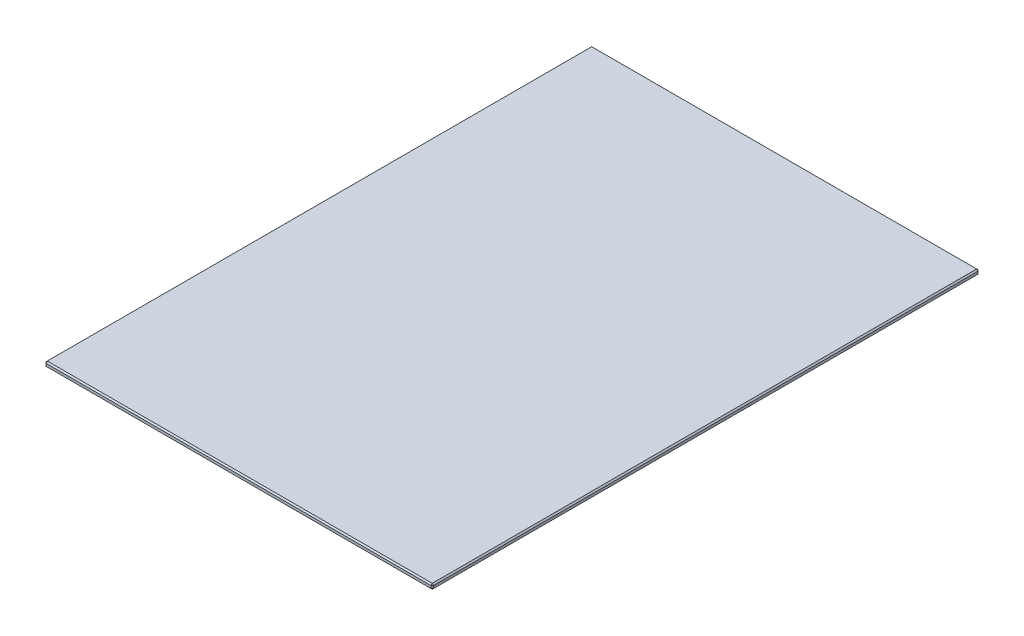
from build123d import *

# Parameters (mm, degrees)
CROQUIS1_W              = 299
CROQUIS1_H              = 422
SALIENTE_EXTRUIR1_DEPTH = 4
CHAFL_N1_SIZE           = 1


with BuildPart() as part:
    # Croquis1 → Saliente-Extruir1 (new body)
    with BuildSketch(Plane(origin=(0, 0, 0), x_dir=(1, 0, 0), z_dir=(0, 1, 0))):
        Rectangle(CROQUIS1_W, CROQUIS1_H)
    extrude(amount=SALIENTE_EXTRUIR1_DEPTH)

    # Chaflán1
    chafl_n1_edges = [part.edges().sort_by_distance(p)[0] for p in [
        (149.5, 4, 0),
        (0, 4, -211),
        (-149.5, 4, 0),
        (0, 0, -211),
        (149.5, 0, 0),
        (0, 0, 211),
        (-149.5, 0, 0),
        (0, 4, 211),
        (-149.5, 2, -211),
        (149.5, 2, -211),
        (149.5, 2, 211),
        (-149.5, 2, 211),
    ]]
    chamfer(chafl_n1_edges, length=CHAFL_N1_SIZE)


solid = part.part
